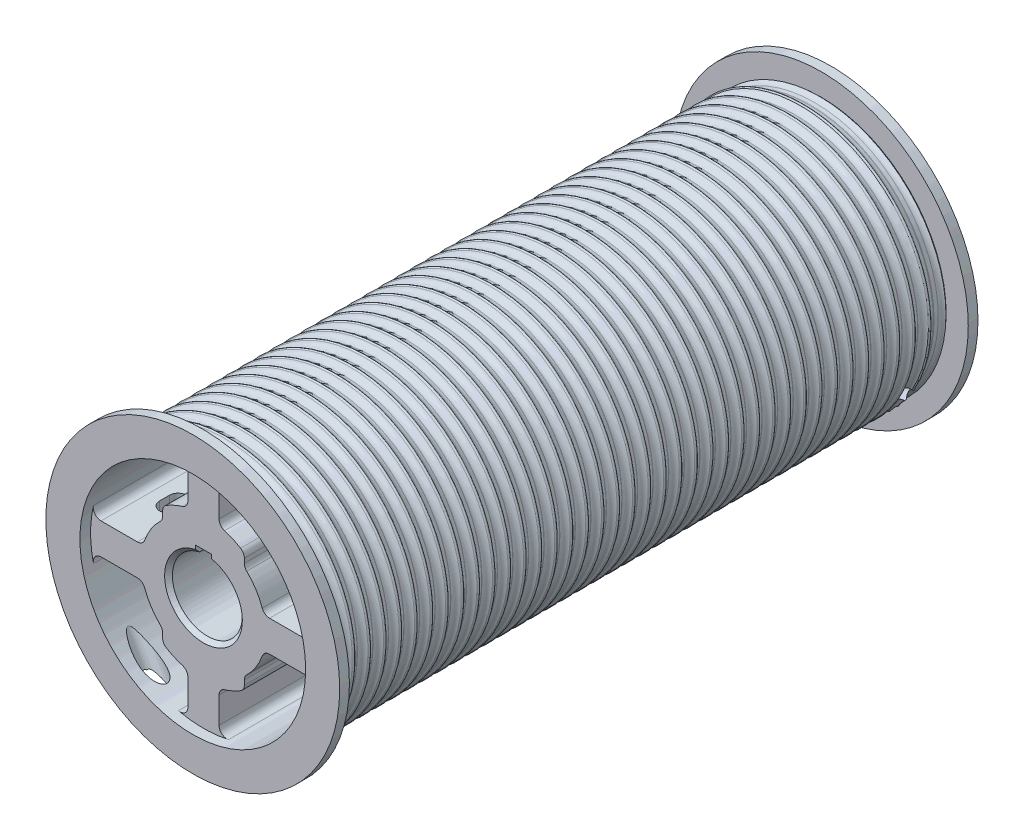
from build123d import *
from build123d.topology import SkipClean

# Parameters (mm, degrees)
SKETCH1_R                       = 100.80625
EXTRUDE1_DEPTH                  = 520.7
SKETCH2_R                       = 119.85625
SKETCH2_R_2                     = 100.80625
EXTRUDE2_DEPTH                  = 7.9375
SKETCH3_R                       = 119.85625
SKETCH3_R_2                     = 100.80625
EXTRUDE3_DEPTH                  = 7.9375
SKETCH4_R                       = 27.00655
CUT_EXTRUDE1_DEPTH              = 521.7
CUT_EXTRUDE2_DEPTH              = 88.9
SKETCH6_R                       = 92.075
CUT_EXTRUDE3_DEPTH              = 8.73125
SKETCH7_R                       = 92.075
CUT_EXTRUDE4_DEPTH              = 8.73125
LPATTERN1_COUNT                 = 40
LPATTERN1_PITCH                 = 12.7
CUT_EXTRUDE5_REACH              = 165.338
SKETCH10_R                      = 7.9375
CHAMFER1_SIZE                   = 3.175
F_17_32_DRILL_REACH             = 268.605
SKETCH44_R                      = 6.746875
F_17_32_DRILL_DIRECTION_2_DEPTH = 65.9920516
CUT_EXTRUDE7_DEPTH              = 12.7


with BuildPart() as part:
    # Sketch1 → Extrude1 (new body)
    with BuildSketch(Plane.XY):
        Circle(SKETCH1_R)
        with BuildLine():
            Line((-12.7, 62.237289114), (-12.7, 83.58153579))
            ThreePointArc((-12.7, 83.58153579), (-15.090079266, 88.545559136), (-20.461111111, 89.772760663))
            ThreePointArc((-20.461111111, 89.772760663), (-65.106856878, 65.106856878), (-89.772760663, 20.461111111))
            ThreePointArc((-89.772760663, 20.461111111), (-88.545559136, 15.090079266), (-83.58153579, 12.7))
            Line((-83.58153579, 12.7), (-53.908476747, 12.7))
            ThreePointArc((-53.908476747, 12.7), (-50.241895388, 13.865534633), (-47.921306962, 16.934273656))
            ThreePointArc((-47.921306962, 16.934273656), (-42.745227884, 27.496668495), (-35.279736784, 36.586356168))
            ThreePointArc((-35.279736784, 36.586356168), (-33.843195233, 38.674100843), (-33.3375, 41.157365184))
            Line((-33.3375, 41.157365184), (-33.3375, 44.901280605))
            ThreePointArc((-33.3375, 44.901280605), (-32.514465577, 48.027804476), (-30.258712121, 50.343860073))
            ThreePointArc((-30.258712121, 50.343860073), (-23.902975766, 53.653906249), (-17.191463415, 56.165358469))
            ThreePointArc((-17.191463415, 56.165358469), (-13.944894354, 58.460995118), (-12.7, 62.237289114))
        make_face(mode=Mode.SUBTRACT)
        with BuildLine():
            Line((12.7, 62.237289114), (12.7, 83.58153579))
            ThreePointArc((12.7, 83.58153579), (15.090079266, 88.545559136), (20.461111111, 89.772760663))
            ThreePointArc((20.461111111, 89.772760663), (65.106856878, 65.106856878), (89.772760663, 20.461111111))
            ThreePointArc((89.772760663, 20.461111111), (88.545559136, 15.090079266), (83.58153579, 12.7))
            Line((83.58153579, 12.7), (53.908476747, 12.7))
            ThreePointArc((53.908476747, 12.7), (50.241895388, 13.865534633), (47.921306962, 16.934273656))
            ThreePointArc((47.921306962, 16.934273656), (42.745227884, 27.496668495), (35.279736784, 36.586356168))
            ThreePointArc((35.279736784, 36.586356168), (33.843195233, 38.674100843), (33.3375, 41.157365184))
            Line((33.3375, 41.157365184), (33.3375, 44.901280605))
            ThreePointArc((33.3375, 44.901280605), (32.514465577, 48.027804476), (30.258712121, 50.343860073))
            ThreePointArc((30.258712121, 50.343860073), (23.902975766, 53.653906249), (17.191463415, 56.165358469))
            ThreePointArc((17.191463415, 56.165358469), (13.944894354, 58.460995118), (12.7, 62.237289114))
        make_face(mode=Mode.SUBTRACT)
        with BuildLine():
            Line((-53.908476747, -12.7), (-83.58153579, -12.7))
            ThreePointArc((-83.58153579, -12.7), (-88.545559136, -15.090079266), (-89.772760663, -20.461111111))
            ThreePointArc((-89.772760663, -20.461111111), (-65.106856878, -65.106856878), (-20.461111111, -89.772760663))
            ThreePointArc((-20.461111111, -89.772760663), (-15.090079266, -88.545559136), (-12.7, -83.58153579))
            Line((-12.7, -83.58153579), (-12.7, -62.237289114))
            ThreePointArc((-12.7, -62.237289114), (-13.944894354, -58.460995118), (-17.191463415, -56.165358469))
            ThreePointArc((-17.191463415, -56.165358469), (-23.902975766, -53.653906249), (-30.258712121, -50.343860073))
            ThreePointArc((-30.258712121, -50.343860073), (-32.514465577, -48.027804476), (-33.3375, -44.901280605))
            Line((-33.3375, -44.901280605), (-33.3375, -41.157365184))
            ThreePointArc((-33.3375, -41.157365184), (-33.843195233, -38.674100843), (-35.279736784, -36.586356168))
            ThreePointArc((-35.279736784, -36.586356168), (-42.745227884, -27.496668495), (-47.921306962, -16.934273656))
            ThreePointArc((-47.921306962, -16.934273656), (-50.241895388, -13.865534633), (-53.908476747, -12.7))
        make_face(mode=Mode.SUBTRACT)
        with BuildLine():
            Line((12.7, -62.237289114), (12.7, -83.58153579))
            ThreePointArc((12.7, -83.58153579), (15.090079266, -88.545559136), (20.461111111, -89.772760663))
            ThreePointArc((20.461111111, -89.772760663), (65.106856878, -65.106856878), (89.772760663, -20.461111111))
            ThreePointArc((89.772760663, -20.461111111), (88.545559136, -15.090079266), (83.58153579, -12.7))
            Line((83.58153579, -12.7), (53.908476747, -12.7))
            ThreePointArc((53.908476747, -12.7), (50.241895388, -13.865534633), (47.921306962, -16.934273656))
            ThreePointArc((47.921306962, -16.934273656), (42.745227884, -27.496668495), (35.279736784, -36.586356168))
            ThreePointArc((35.279736784, -36.586356168), (33.843195233, -38.674100843), (33.3375, -41.157365184))
            Line((33.3375, -41.157365184), (33.3375, -44.901280605))
            ThreePointArc((33.3375, -44.901280605), (32.514465577, -48.027804476), (30.258712121, -50.343860073))
            ThreePointArc((30.258712121, -50.343860073), (23.902975766, -53.653906249), (17.191463415, -56.165358469))
            ThreePointArc((17.191463415, -56.165358469), (13.944894354, -58.460995118), (12.7, -62.237289114))
        make_face(mode=Mode.SUBTRACT)
    extrude(amount=-EXTRUDE1_DEPTH)

    # Sketch2 → Extrude2 (add)
    with BuildSketch(Plane.XY):
        Circle(SKETCH2_R)
        Circle(SKETCH2_R_2, mode=Mode.SUBTRACT)
    extrude(amount=-EXTRUDE2_DEPTH)

    # Sketch3 → Extrude3 (add)
    with BuildSketch(Plane.XY.offset(-520.7)):
        Circle(SKETCH3_R)
        Circle(SKETCH3_R_2, mode=Mode.SUBTRACT)
    extrude(amount=EXTRUDE3_DEPTH)

    # Sketch4 → Cut-Extrude1 (cut, through all)
    with BuildSketch(Plane.XY.offset(-520.7)):
        Circle(SKETCH4_R)
    extrude(amount=CUT_EXTRUDE1_DEPTH, mode=Mode.SUBTRACT)

    # Sketch5 → Cut-Extrude2 (cut)
    with BuildSketch(Plane.XY):
        with BuildLine():
            Line((6.35, 27.814920156), (6.35, 34.215720156))
            Line((6.35, 34.215720156), (-6.35, 34.215720156))
            Line((-6.35, 34.215720156), (-6.35, 27.814920156))
            ThreePointArc((-6.35, 27.814920156), (0, -28.53055), (6.35, 27.814920156))
        make_face()
    extrude(amount=-CUT_EXTRUDE2_DEPTH, mode=Mode.SUBTRACT)

    # Sketch6 → Cut-Extrude3 (cut)
    with BuildSketch(Plane.XY):
        Circle(SKETCH6_R)
    extrude(amount=-CUT_EXTRUDE3_DEPTH, mode=Mode.SUBTRACT)

    # Sketch7 → Cut-Extrude4 (cut)
    with SkipClean():  # keep this step's faces unmerged: merging them makes the solid invalid here
        with BuildSketch(Plane.XY.offset(-520.7)):
            Circle(SKETCH7_R)
        extrude(amount=CUT_EXTRUDE4_DEPTH, mode=Mode.SUBTRACT)

    # Sketch8 → Revolve1 (revolve)
    with BuildSketch(Plane(origin=(0, 0, 0), x_dir=(0, 0, -1), z_dir=(1, 0, 0)), mode=Mode.PRIVATE) as revolve1_sk:
        with BuildLine():
            ThreePointArc((13.375849908, 104.110192603), (11.231697367, 101.728479679), (8.162586913, 100.80625))
            Line((8.162586913, 100.80625), (20.6375, 100.80625))
            ThreePointArc((20.6375, 100.80625), (17.568389545, 101.728479679), (15.424237005, 104.110192603))
            ThreePointArc((15.424237005, 104.110192603), (14.400043456, 104.745771106), (13.375849908, 104.110192603))
        make_face()
    revolve1 = revolve(revolve1_sk.sketch.rotate(Axis((0, 0, -805.823131844), (0, 0, 1)), 270), axis=Axis((0, 0, -805.823131844), (0, 0, 1)))  # turned: the seam where the file's is

    # LPattern1: Revolve1 ×40
    with Locations(*[(0, 0, -i * LPATTERN1_PITCH) for i in range(1, LPATTERN1_COUNT)]):
        add(revolve1)

    # Sketch9 → Cut-Revolve1 (revolve, cut)
    with BuildSketch(Plane(origin=(0, 0, 0), x_dir=(0, 0, -1), z_dir=(1, 0, 0)), mode=Mode.PRIVATE) as cut_revolve1_sk:
        with BuildLine():
            Line((13.420876375, 100.80625), (16.820963288, 100.80625))
            ThreePointArc((16.820963288, 100.80625), (20.176357967, 101.921799194), (22.304339663, 104.745771106))
            Line((22.304339663, 104.745771106), (7.9375, 104.745771106))
            ThreePointArc((7.9375, 104.745771106), (10.065481696, 101.921799194), (13.420876375, 100.80625))
        make_face()
        with BuildLine():
            Line((503.879036712, 100.810078894), (507.279123625, 100.810078894))
            ThreePointArc((507.279123625, 100.810078894), (510.634518304, 101.925628088), (512.7625, 104.7496))
            Line((512.7625, 104.7496), (498.395660337, 104.7496))
            ThreePointArc((498.395660337, 104.7496), (500.523642033, 101.925628088), (503.879036712, 100.810078894))
        make_face()
    revolve(cut_revolve1_sk.sketch.rotate(Axis((0, 0, -805.823131844), (0, 0, 1)), 90), axis=Axis((0, 0, -805.823131844), (0, 0, 1)), mode=Mode.SUBTRACT)  # turned: the seam where the file's is

    # Sketch10 → Cut-Extrude5 (cut, up to next)
    with BuildSketch(Plane(origin=(0, 0, 0), x_dir=(-0.870355696, -0.49242356, 0), z_dir=(-0.49242356, 0.870355696, 0)), mode=Mode.PRIVATE) as cut_extrude5_sk1:
        with Locations((82.55, -17.4625)):
            Circle(SKETCH10_R)
    cut_extrude5_tool1 = extrude(cut_extrude5_sk1.sketch, amount=-CUT_EXTRUDE5_REACH, mode=Mode.PRIVATE) & part.part
    add(cut_extrude5_tool1.solids().sort_by_distance((-71.847863, -40.649565, -17.4625))[0], mode=Mode.SUBTRACT)

    # Chamfer1
    chamfer1_edges = [part.edges().sort_by_distance(p)[0] for p in [
        (0, -28.53055, -8.73125),
        (-27.00655, 0, -511.96875),
    ]]
    chamfer(chamfer1_edges, length=CHAMFER1_SIZE)

    # Sketch42 → 1/2-13 Tapped Hole6 (revolve, cut)
    with SkipClean():  # keep this step's faces unmerged: merging them makes the solid invalid here
        with BuildSketch(Plane(origin=(84.54323494, -54.903018723, -493.7125), x_dir=(0.544639035, 0.838670568, 0), z_dir=(0, 0, 1))):
            Polygon((0, 0), (0, 104.819489309), (5.35813, 101.6), (5.35813, 25.4), (6.35, 25.4), (6.35, 0), align=None)
        revolve(axis=Axis((89.868793046, -58.361476596, -493.7125), (-0.838670568, 0.544639035, 0)), mode=Mode.SUBTRACT)

    # Sketch44 → 17/32 DRILL (cut, up to next)
    with BuildSketch(Plane(origin=(84.54323494, -54.903018723, 0), x_dir=(-0.544639035, -0.838670568, 0), z_dir=(-0.838670568, 0.544639035, 0)), mode=Mode.PRIVATE) as f_17_32_drill_sk1:
        with Locations(Location((0, -493.7125, 0), (0, 0, 340.399097444))):  # turned: the seam where the file's is
            Circle(SKETCH44_R)
    f_17_32_drill_tool1 = extrude(f_17_32_drill_sk1.sketch, amount=F_17_32_DRILL_REACH, mode=Mode.PRIVATE) & part.part
    add(f_17_32_drill_tool1.solids().sort_by_distance((84.543235, -54.903019, -493.7125))[0], mode=Mode.SUBTRACT)

    # Sketch44 → 17/32 DRILL direction 2 (cut)
    with SkipClean():  # keep this step's faces unmerged: merging them makes the solid invalid here
        with BuildSketch(Plane(origin=(84.54323494, -54.903018723, 0), x_dir=(-0.544639035, -0.838670568, 0), z_dir=(-0.838670568, 0.544639035, 0))):
            with Locations(Location((0, -493.7125, 0), (0, 0, 340.399097444))):  # turned: the seam where the file's is
                Circle(SKETCH44_R)
        extrude(amount=-F_17_32_DRILL_DIRECTION_2_DEPTH, mode=Mode.SUBTRACT)

    # Sketch45 → Cut-Revolve2 (revolve, cut)
    with SkipClean():  # keep this step's faces unmerged: merging them makes the solid invalid here
        with BuildSketch(Plane(origin=(0, 0, 0), x_dir=(0, 0, -1), z_dir=(1, 0, 0)), mode=Mode.PRIVATE) as cut_revolve2_sk:
            with BuildLine():
                Line((435.77002, 0), (435.77002, 39.6875))
                Line((435.77002, 39.6875), (280.709327159, 72.745856375))
                ThreePointArc((280.709327159, 72.745856375), (279.392623293, 72.955021298), (278.061247307, 73.025))
                Line((278.061247307, 73.025), (242.638752693, 73.025))
                ThreePointArc((242.638752693, 73.025), (241.307376707, 72.955021298), (239.990672841, 72.745856375))
                Line((239.990672841, 72.745856375), (84.92998, 39.6875))
                Line((84.92998, 39.6875), (84.92998, 0))
                Line((84.92998, 0), (435.77002, 0))
            make_face()
        revolve(cut_revolve2_sk.sketch.rotate(Axis((0, 0, -805.823131844), (0, 0, 1)), 90), axis=Axis((0, 0, -805.823131844), (0, 0, 1)), mode=Mode.SUBTRACT)  # turned: the seam where the file's is

    # Sketch46 → Cut-Extrude7 (cut, symmetric)
    with SkipClean():  # keep this step's faces unmerged: merging them makes the solid invalid here
        with BuildSketch(Plane(origin=(0, 0, 0), x_dir=(-1, 0, 0), z_dir=(0, 1, 0))):
            with BuildLine():
                Line((-59.53125, -46.83125), (-59.53125, -54.76875))
                ThreePointArc((-59.53125, -54.76875), (-66.675, -61.9125), (-73.81875, -54.76875))
                Line((-73.81875, -54.76875), (-73.81875, -46.83125))
                ThreePointArc((-73.81875, -46.83125), (-66.675, -39.6875), (-59.53125, -46.83125))
            make_face()
            with BuildLine():
                Line((-59.53125, -465.9249), (-59.53125, -473.8624))
                ThreePointArc((-59.53125, -473.8624), (-66.675, -481.00615), (-73.81875, -473.8624))
                Line((-73.81875, -473.8624), (-73.81875, -465.9249))
                ThreePointArc((-73.81875, -465.9249), (-66.675, -458.78115), (-59.53125, -465.9249))
            make_face()
        cut_extrude7 = extrude(amount=CUT_EXTRUDE7_DEPTH, both=True, mode=Mode.SUBTRACT)

    # Mirror1: Cut-Extrude7 across plane
    with SkipClean():  # keep this step's faces unmerged: merging them makes the solid invalid here
        add(cut_extrude7.mirror(Plane(origin=(0, 0, 0), x_dir=(0, 0, 1), z_dir=(1, 0, 0))), mode=Mode.SUBTRACT)


solid = part.part
